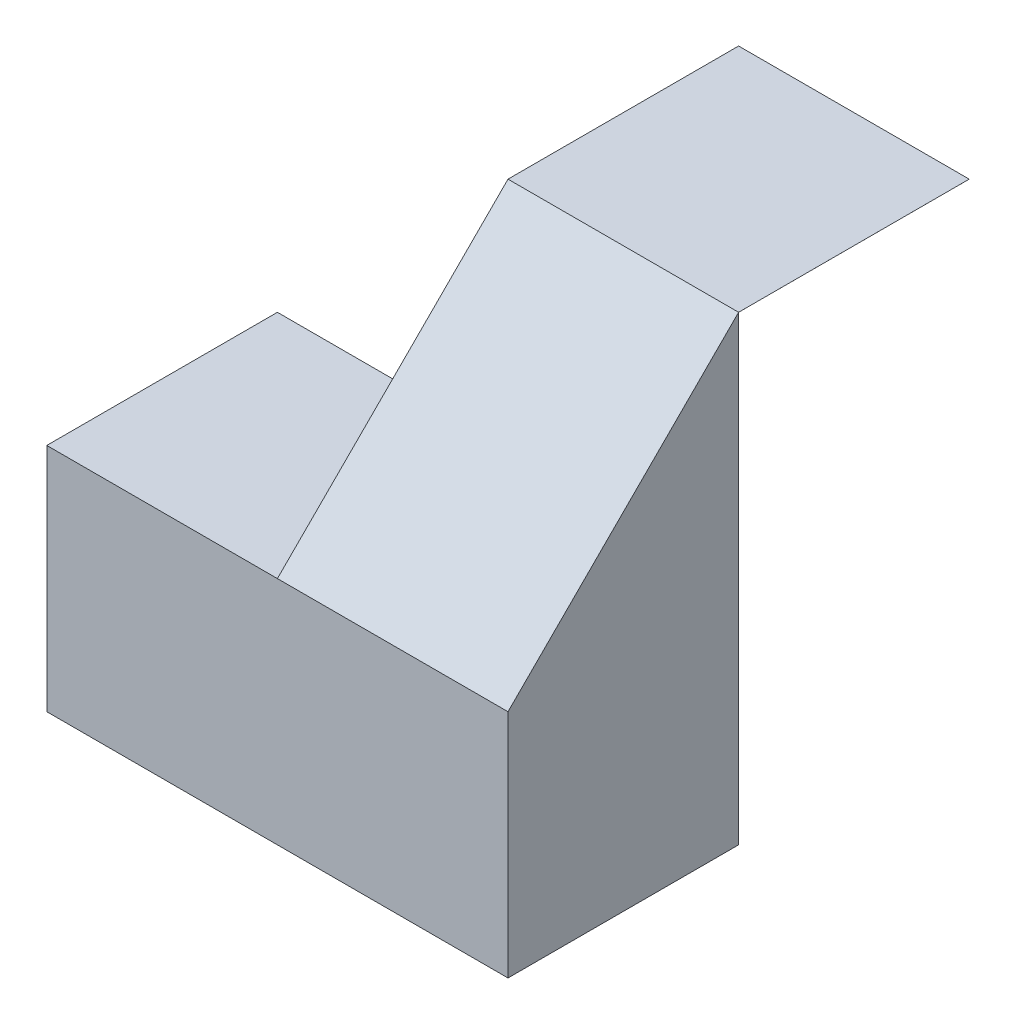
from build123d import *

# Parameters (mm, degrees)
SKETCH1_W           = 40
SKETCH1_H           = 40
BOSS_EXTRUDE1_DEPTH = 40
SKETCH2_W           = 20
SKETCH2_H           = 20
CUT_EXTRUDE1_DEPTH  = 40
CUT_EXTRUDE2_DEPTH  = 40
SKETCH4_W           = 20
SKETCH4_H           = 20
CUT_EXTRUDE4_DEPTH  = 19.999
CUT_EXTRUDE6_DEPTH  = 19.999
CUT_EXTRUDE7_DEPTH  = 19.999
SKETCH7_W           = 19.9999
SKETCH7_H           = 19.999
CUT_EXTRUDE8_DEPTH  = 19.999
CUT_EXTRUDE9_DEPTH  = 19.999
CUT_EXTRUDE10_DEPTH = 0.0001


with BuildPart() as part:
    # Sketch1 → Boss-Extrude1 (new body)
    with BuildSketch(Plane.XY):
        with Locations((20, 20)):
            Rectangle(SKETCH1_W, SKETCH1_H)
    extrude(amount=BOSS_EXTRUDE1_DEPTH)

    # Sketch2 → Cut-Extrude1 (cut)
    with BuildSketch(Plane.XY.offset(40)):
        with Locations((10, 30)):
            Rectangle(SKETCH2_W, SKETCH2_H)
    extrude(amount=-CUT_EXTRUDE1_DEPTH, mode=Mode.SUBTRACT)

    # Sketch3 → Cut-Extrude2 (cut)
    with BuildSketch(Plane.ZY.offset(-20)):
        Polygon((40, 20), (20, 40), (40, 40), align=None)
    extrude(amount=-CUT_EXTRUDE2_DEPTH, mode=Mode.SUBTRACT)

    # Sketch4 → Cut-Extrude4 (cut)
    with BuildSketch(Plane(origin=(40, 0, 0), x_dir=(0, 0, -1), z_dir=(1, 0, 0))):
        with Locations((-10, 10)):
            Rectangle(SKETCH4_W, SKETCH4_H)
    extrude(amount=-CUT_EXTRUDE4_DEPTH, mode=Mode.SUBTRACT)

    # Sketch5 → Cut-Extrude6 (cut)
    with BuildSketch(Plane(origin=(0, 0, 0), x_dir=(-1, 0, 0), z_dir=(0, 0, -1))):
        Polygon((-39.9999, 39.999), (-20.0001, 20.001), (-39.9999, 20.001), align=None)
    extrude(amount=-CUT_EXTRUDE6_DEPTH, mode=Mode.SUBTRACT)

    # Sketch6 → Cut-Extrude7 (cut)
    with BuildSketch(Plane.ZY.offset(-39.9999)):
        Polygon((0, 20.001), (19.999, 20.001), (20, 39.999), (0, 39.999), align=None)
    extrude(amount=-CUT_EXTRUDE7_DEPTH, mode=Mode.SUBTRACT)

    # Sketch7 → Cut-Extrude8 (cut)
    with BuildSketch(Plane(origin=(0, 20.001, 0), x_dir=(1, 0, 0), z_dir=(0, 1, 0))):
        with Locations((30.00005, -9.9995)):
            Rectangle(SKETCH7_W, SKETCH7_H)
    extrude(amount=-CUT_EXTRUDE8_DEPTH, mode=Mode.SUBTRACT)

    # Sketch8 → Cut-Extrude9 (cut)
    with BuildSketch(Plane.ZY):
        Polygon((0, 0), (20, 20), (0, 20), align=None)
    extrude(amount=-CUT_EXTRUDE9_DEPTH, mode=Mode.SUBTRACT)

    # Sketch9 → Cut-Extrude10 (cut)
    with BuildSketch(Plane.ZY.offset(-20)):
        Polygon((20, 40), (20, 20), (40, 20), align=None)
    extrude(amount=-CUT_EXTRUDE10_DEPTH, mode=Mode.SUBTRACT)


solid = part.part
